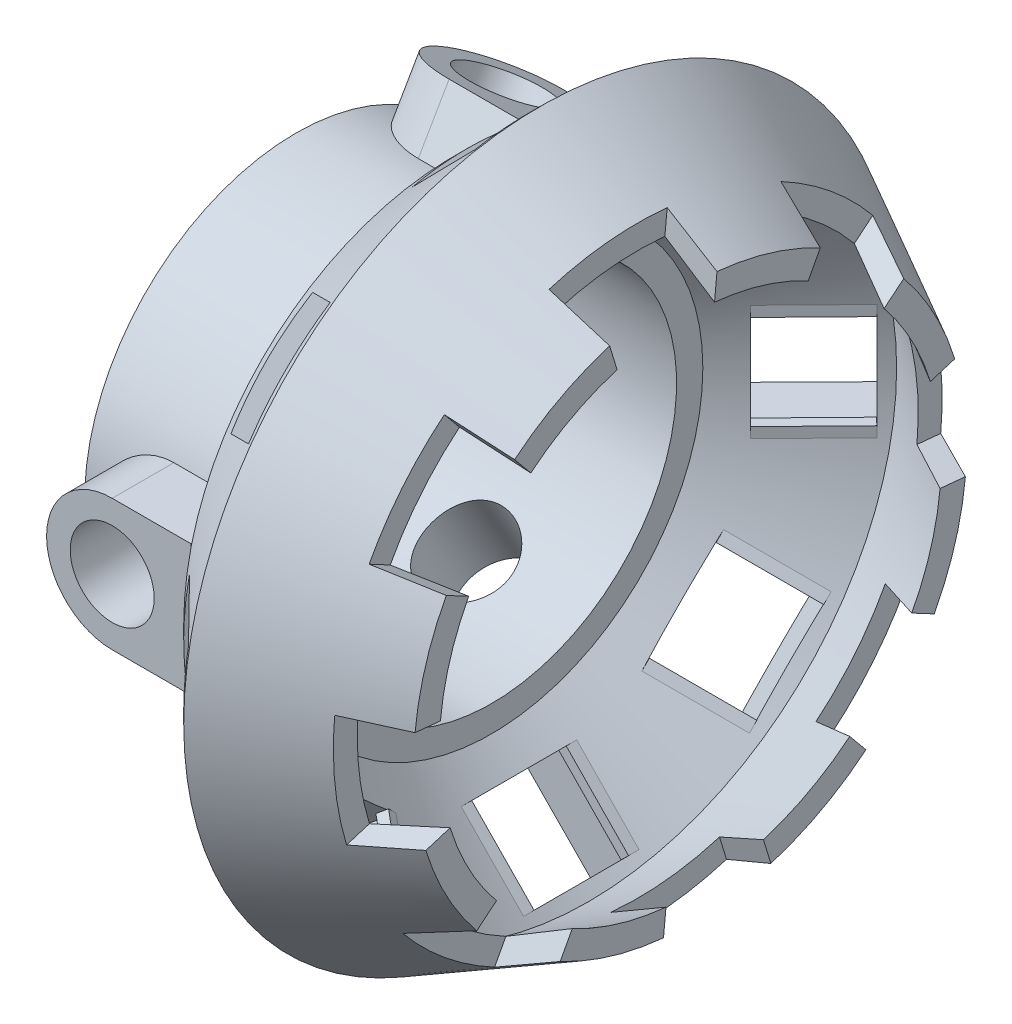
from build123d import *

# Parameters (mm, degrees)
CUT_EXTRUDE_1_DEPTH      = 1.1
PATTERN_CIRCULAR_1_COUNT = 8
SKETCH_5_W               = 1.700120055
SKETCH_5_H               = 0.2
EXTRUDE_1_DEPTH          = 0.2
SKETCH_6_W               = 6.063868524
SKETCH_6_H               = 11.227162516
SKETCH_6_W_2             = 3.422183227
SKETCH_6_H_2             = 15.129652159
CUT_EXTRUDE_2_DEPTH      = 10
SKETCH_7_W               = 0.2
SKETCH_7_H               = 1.700120055
EXTRUDE_2_DEPTH          = 0.2
PATTERN_CIRCULAR_2_COUNT = 8
CUT_EXTRUDE_3_DEPTH      = 1
SKETCH_10_R              = 0.8
EXTRUDE_3_DEPTH          = 1.3
SKETCH_11_R              = 0.8
CUT_EXTRUDE_4_DEPTH      = 1.8
PATTERN_CIRCULAR_5_COUNT = 3


with BuildPart() as part:
    # 草图1 → 旋转1 (revolve)
    with BuildSketch(Plane.XY, mode=Mode.PRIVATE) as revolve_1_sk:
        Polygon((0.787641047, 3.525), (4.357609697, 3.525), (4.769072518, 3.525), (6.850341839, 3.525), (6.850341839, 4.025), (8.696052517, 5.870710678), (11.135392345, 4.5), (11.135392345, 5), (7.774589765, 6.787725558), (6.124874831, 5.138010624), (6.124874831, 4.025), (4.787641047, 4.025), (0.787641047, 4.025), align=None)
    revolve(revolve_1_sk.sketch.rotate(Axis((0, 0, 0), (1, 0, 0)), 90), axis=Axis((0, 0, 0), (1, 0, 0)))

    # 草图2 → 切除-拉伸1 (cut, symmetric)
    with BuildSketch(Plane(origin=(0, 0, 0), x_dir=(1, 0, 0), z_dir=(0, 1, 0))):
        Polygon((5.276599776, -6.508182903), (7.495047111, -4.289735569), (8.697128639, -5.491817097), (6.478681304, -7.710264431), align=None)
    cut_extrude_1 = extrude(amount=CUT_EXTRUDE_1_DEPTH, both=True, mode=Mode.SUBTRACT)

    # 阵列(圆周)1: 切除-拉伸1 ×8 about axis
    pattern_circular_1_axis = Axis((0, 0, 0), (1, 0, 0))
    for i in range(1, PATTERN_CIRCULAR_1_COUNT):
        add(cut_extrude_1.rotate(pattern_circular_1_axis, i * 360 / PATTERN_CIRCULAR_1_COUNT), mode=Mode.SUBTRACT)

    # 草图5 → 凸台-拉伸1 (add)
    with BuildSketch(Plane(origin=(1.568429235, 0, -1.531586465), x_dir=(-0.6986536869070339, 0, -0.7154600099035644), z_dir=(0.7154600099035644, 0, -0.6986536869070339))):
        with Locations((-9.157694652, 1)):
            Rectangle(SKETCH_5_W, SKETCH_5_H)
        with Locations((-9.157694652, -1)):
            Rectangle(SKETCH_5_W, SKETCH_5_H)
    extrude(amount=-EXTRUDE_1_DEPTH)

    # 草图6 → 切除-拉伸2 (cut, symmetric)
    with BuildSketch(Plane.XY):
        with Locations((0.092940569, 0.100063837)):
            Rectangle(SKETCH_6_W, SKETCH_6_H)
        with Locations((12.346483959, -0.150095755)):
            Rectangle(SKETCH_6_W_2, SKETCH_6_H_2)
    extrude(amount=CUT_EXTRUDE_2_DEPTH, both=True, mode=Mode.SUBTRACT)

    # 草图7 → 凸台-拉伸2 (add)
    with BuildSketch(Plane(origin=(1.568429235, -1.531586465, 0), x_dir=(0, 0, 1), z_dir=(-0.7154600099035651, 0.6986536869070332, 8.545512237037213e-15))):
        with Locations((1, 9.157694652)):
            Rectangle(SKETCH_7_W, SKETCH_7_H)
        with Locations((-1, 9.157694652)):
            Rectangle(SKETCH_7_W, SKETCH_7_H)
    extrude_2 = extrude(amount=EXTRUDE_2_DEPTH)

    # 阵列(圆周)2: 凸台-拉伸2 ×8 about axis
    pattern_circular_2_axis = Axis((0, 0, 0), (1, 0, 0))
    for i in range(1, PATTERN_CIRCULAR_2_COUNT):
        add(extrude_2.rotate(pattern_circular_2_axis, i * 360 / PATTERN_CIRCULAR_2_COUNT))

    # 草图9 → 切除-拉伸3 (cut)
    with BuildSketch(Plane(origin=(10.635392345, 0, 0), x_dir=(0, 0, -1), z_dir=(1, 0, 0))):
        with BuildLine():
            Line((-2.197785116, 7.210789857), (0, 0))
            Line((0, 0), (0.728961128, 7.502957114))
            ThreePointArc((0.728961128, 7.502957114), (-0.748799976, 7.501003158), (-2.197785116, 7.210789857))
        make_face()
        with BuildLine():
            Line((3.544729647, 6.652867165), (0, 0))
            Line((0, 0), (5.820845211, 4.789938498))
            ThreePointArc((5.820845211, 4.789938498), (4.774528658, 5.833491739), (3.544729647, 6.652867165))
        make_face()
        with BuildLine():
            Line((7.210789857, 2.197785116), (0, 0))
            Line((0, 0), (7.502957114, -0.728961128))
            ThreePointArc((7.502957114, -0.728961128), (7.501003158, 0.748799976), (7.210789857, 2.197785116))
        make_face()
        with BuildLine():
            Line((6.652867165, -3.544729647), (0, 0))
            Line((0, 0), (4.789938498, -5.820845211))
            ThreePointArc((4.789938498, -5.820845211), (5.833491739, -4.774528658), (6.652867165, -3.544729647))
        make_face()
        with BuildLine():
            Line((2.197785116, -7.210789857), (0, 0))
            Line((0, 0), (-0.728961128, -7.502957114))
            ThreePointArc((-0.728961128, -7.502957114), (0.748799976, -7.501003158), (2.197785116, -7.210789857))
        make_face()
        with BuildLine():
            Line((-3.544729647, -6.652867165), (0, 0))
            Line((0, 0), (-5.820845211, -4.789938498))
            ThreePointArc((-5.820845211, -4.789938498), (-4.774528658, -5.833491739), (-3.544729647, -6.652867165))
        make_face()
        with BuildLine():
            Line((-7.210789857, -2.197785116), (0, 0))
            Line((0, 0), (-7.502957114, 0.728961128))
            ThreePointArc((-7.502957114, 0.728961128), (-7.501003158, -0.748799976), (-7.210789857, -2.197785116))
        make_face()
        with BuildLine():
            Line((-6.652867165, 3.544729647), (0, 0))
            Line((0, 0), (-4.789938498, 5.820845211))
            ThreePointArc((-4.789938498, 5.820845211), (-5.833491739, 4.774528658), (-6.652867165, 3.544729647))
        make_face()
    extrude(amount=-CUT_EXTRUDE_3_DEPTH, mode=Mode.SUBTRACT)

    # 草图10 → 凸台-拉伸3 (add)
    with BuildSketch(Plane.XY.offset(5)):
        with BuildLine():
            Line((4.624874831, -1.25), (6.124874831, -1.25))
            Line((6.124874831, -1.25), (6.124874831, 1.25))
            Line((6.124874831, 1.25), (4.624874831, 1.25))
            ThreePointArc((4.624874831, 1.25), (3.374874831, 0), (4.624874831, -1.25))
        make_face()
        with Locations((4.624874831, 0)):
            Circle(SKETCH_10_R, mode=Mode.SUBTRACT)
    extrude_3 = extrude(amount=-EXTRUDE_3_DEPTH)

    # 草图11 → 切除-拉伸4 (cut)
    with BuildSketch(Plane.XY.offset(5)):
        with Locations((4.624874831, 0)):
            Circle(SKETCH_11_R)
    cut_extrude_4 = extrude(amount=-CUT_EXTRUDE_4_DEPTH, mode=Mode.SUBTRACT)

    # 阵列(圆周)5: 凸台-拉伸3, 切除-拉伸4 ×3 about axis
    pattern_circular_5_axis = Axis((0, 0, 0), (1, 0, 0))
    add([extrude_3.rotate(pattern_circular_5_axis, i * 360 / PATTERN_CIRCULAR_5_COUNT) for i in range(1, PATTERN_CIRCULAR_5_COUNT)])
    add([cut_extrude_4.rotate(pattern_circular_5_axis, i * 360 / PATTERN_CIRCULAR_5_COUNT) for i in range(1, PATTERN_CIRCULAR_5_COUNT)], mode=Mode.SUBTRACT)


solid = part.part
